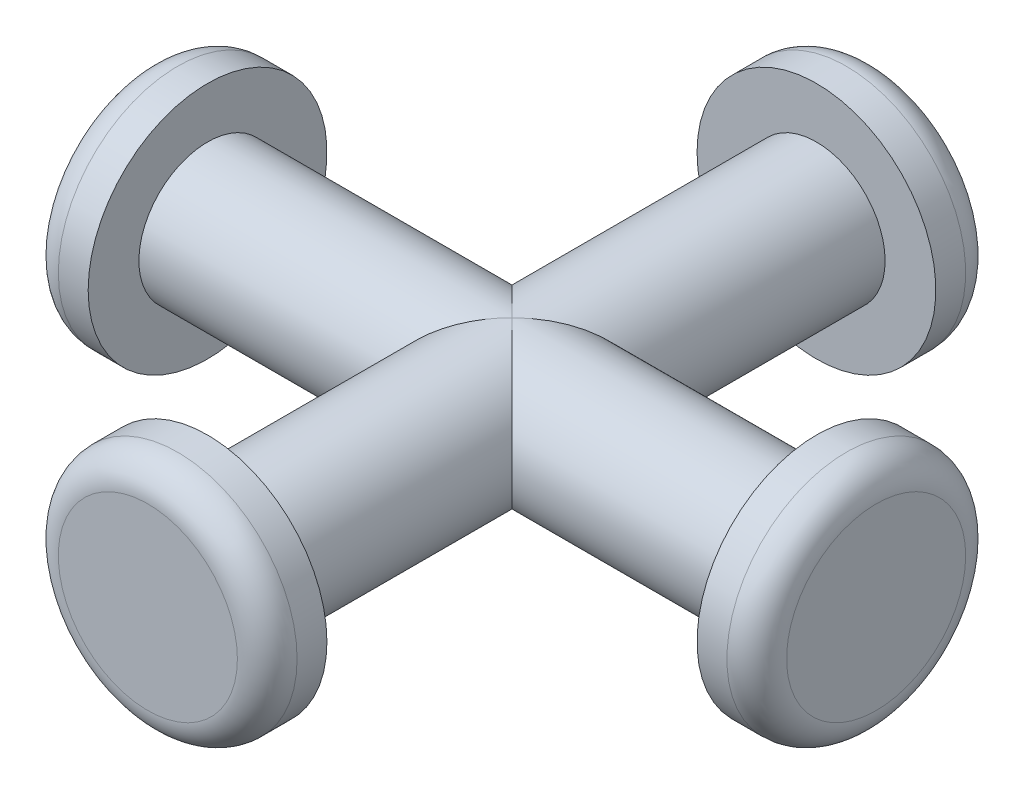
from build123d import *

# Parameters (mm, degrees)
ESQUISSE1_R        = 2.3
BOSS_EXTRU_1_DEPTH = 10.2
ESQUISSE3_R        = 2.3
BOSS_EXTRU_2_DEPTH = 10.2
ESQUISSE4_R        = 4
BOSS_EXTRU_3_DEPTH = 2
ESQUISSE5_R        = 4
BOSS_EXTRU_4_DEPTH = 2
ESQUISSE6_R        = 4
BOSS_EXTRU_5_DEPTH = 2
ESQUISSE7_R        = 4
BOSS_EXTRU_6_DEPTH = 2
CONG_1_R           = 1


with BuildPart() as part:
    # Esquisse1 → Boss.-Extru.1 (new body, symmetric)
    with BuildSketch(Plane.XY):
        Circle(ESQUISSE1_R)
    extrude(amount=BOSS_EXTRU_1_DEPTH, both=True)

    # Esquisse3 → Boss.-Extru.2 (add, symmetric)
    with BuildSketch(Plane(origin=(0, 0, 0), x_dir=(0, 0, -1), z_dir=(1, 0, 0))):
        with Locations(Location((0, 0, 0), (0, 0, 270))):  # turned: the seam where the file's is
            Circle(ESQUISSE3_R)
    extrude(amount=BOSS_EXTRU_2_DEPTH, both=True)

    # Esquisse4 → Boss.-Extru.3 (add)
    with BuildSketch(Plane(origin=(10.2, 0, 0), x_dir=(0, 0, -1), z_dir=(1, 0, 0))):
        Circle(ESQUISSE4_R)
    extrude(amount=BOSS_EXTRU_3_DEPTH)

    # Esquisse5 → Boss.-Extru.4 (add)
    with BuildSketch(Plane.ZY.offset(10.2)):
        with Locations(Location((0, 0, 0), (0, 0, 180))):  # turned: the seam where the file's is
            Circle(ESQUISSE5_R)
    extrude(amount=BOSS_EXTRU_4_DEPTH)

    # Esquisse6 → Boss.-Extru.5 (add)
    with BuildSketch(Plane.XY.offset(10.2)):
        Circle(ESQUISSE6_R)
    extrude(amount=BOSS_EXTRU_5_DEPTH)

    # Esquisse7 → Boss.-Extru.6 (add)
    with BuildSketch(Plane(origin=(0, 0, -10.2), x_dir=(-1, 0, 0), z_dir=(0, 0, -1))):
        with Locations(Location((0, 0, 0), (0, 0, 180))):  # turned: the seam where the file's is
            Circle(ESQUISSE7_R)
    extrude(amount=BOSS_EXTRU_6_DEPTH)

    # Congé1
    cong_1_edges = [part.edges().sort_by_distance(p)[0] for p in [
        (12.2, 0, 4),
        (-12.2, 0, 4),
        (-4, 0, 12.2),
        (-4, 0, -12.2),
    ]]
    fillet(cong_1_edges, radius=CONG_1_R)


solid = part.part
